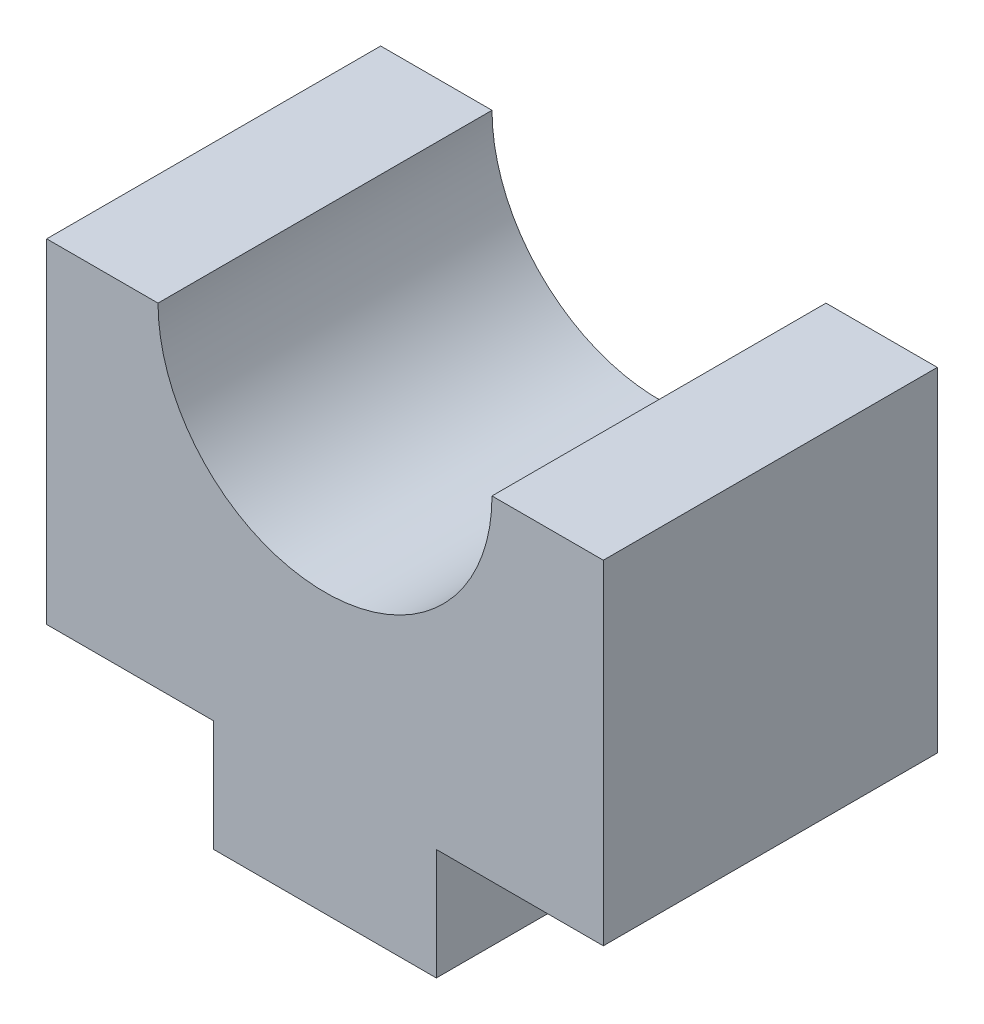
from build123d import *

# Parameters (mm, degrees)
SALIENTE_EXTRUIR1_DEPTH = 15


with BuildPart() as part:
    # Croquis1 → Saliente-Extruir1 (new body)
    with BuildSketch(Plane.XY):
        with BuildLine():
            Line((0, 0), (10, 0))
            Line((10, 0), (10, 5))
            Line((10, 5), (17.5, 5))
            Line((17.5, 5), (17.5, 20))
            Line((17.5, 20), (12.5, 20))
            ThreePointArc((12.5, 20), (5, 12.5), (-2.5, 20))
            Line((-2.5, 20), (-7.5, 20))
            Line((-7.5, 20), (-7.5, 5))
            Line((-7.5, 5), (0, 5))
            Line((0, 5), (0, 0))
        make_face()
    extrude(amount=-SALIENTE_EXTRUIR1_DEPTH)


solid = part.part
